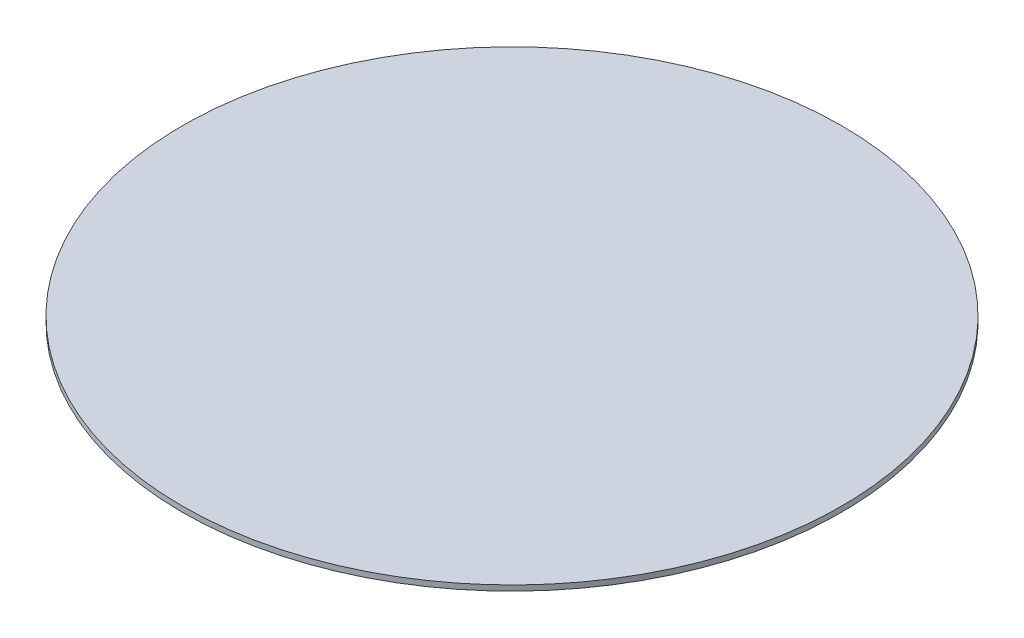
from build123d import *

# Parameters (mm, degrees)
SKETCH1_R           = 127
BOSS_EXTRUDE1_DEPTH = 2.07


with BuildPart() as part:
    # Sketch1 → Boss-Extrude1 (new body)
    with BuildSketch(Plane(origin=(0, 0, 0), x_dir=(1, 0, 0), z_dir=(0, 1, 0))):
        Circle(SKETCH1_R)
    extrude(amount=BOSS_EXTRUDE1_DEPTH)


solid = part.part
